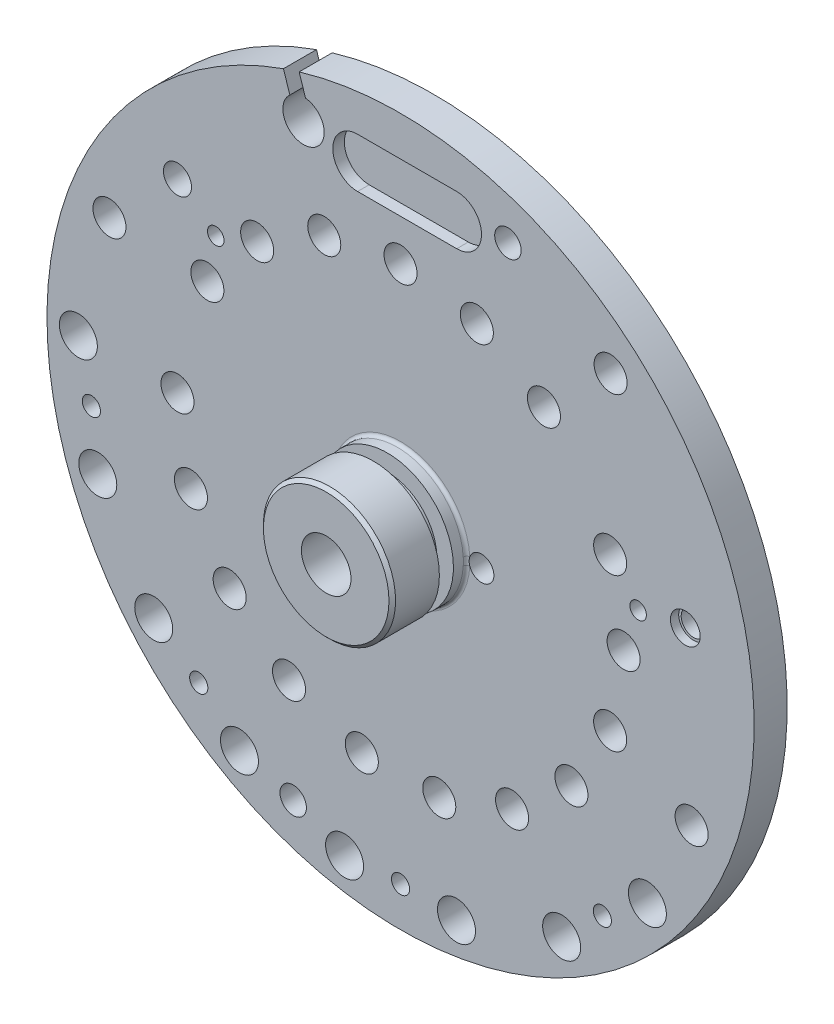
from build123d import *

# Parameters (mm, degrees)
SKETCH1_R                                            = 21.4
BOSS_EXTRUDE1_DEPTH                                  = 2
SKETCH2_R                                            = 6.5
BOSS_EXTRUDE2_DEPTH                                  = 4.7
SKETCH3_R                                            = 4
BOSS_EXTRUDE3_DEPTH                                  = 4.5
SKETCH5_R                                            = 3.25
CUT_EXTRUDE2_DEPTH                                   = 5.2
CUT_EXTRUDE1_REACH                                   = 13.2
SKETCH4_R                                            = 1.5
SKETCH6_W                                            = 0.85
SKETCH6_H                                            = 1
SKETCH7_W                                            = 0.5
SKETCH7_H                                            = 5.5
CUT_EXTRUDE3_DEPTH                                   = 22.4
CUT_EXTRUDE3_DEPTH_BACK                              = 22.4
CUT_EXTRUDE4_DEPTH                                   = 0.7
F_2_0_2_DIAMETER_HOLE6_D                             = 2
FILLET2_R                                            = 1
F_2_3_2_3_DIAMETER_HOLE1_D                           = 2.3
F_2_0_2_DIAMETER_HOLE8_D                             = 2
F_2_5_2_5_DIAMETER_HOLE1_D                           = 2.5
F_1_0_1_DIAMETER_HOLE1_D                             = 1
F_1_7_1_7_DIAMETER_HOLE2_D                           = 1.7
M1_4X0_3_TAPPED_HOLE1_D                              = 1.1
M2_TAPPED_HOLE1_D                                    = 1.6
CBORE_FOR_M1_7_HEX_SOCKET_HEAD_CAP_SCREW_D           = 1.5
CBORE_FOR_M1_7_HEX_SOCKET_HEAD_CAP_SCREW_CBORE_D     = 1.8
CBORE_FOR_M1_7_HEX_SOCKET_HEAD_CAP_SCREW_CBORE_DEPTH = 0.5
CBORE_FOR_M1_7_HEX_SOCKET_HEAD_CAP_S_2_D             = 1.5
CBORE_FOR_M1_7_HEX_SOCKET_HEAD_CAP_S_2_CBORE_D       = 1.8
CBORE_FOR_M1_7_HEX_SOCKET_HEAD_CAP_S_2_CBORE_DEPTH   = 1.2
CUT_EXTRUDE5_DEPTH                                   = 7.5
FILLET3_R                                            = 0.2
CHAMFER1_SIZE                                        = 0.2


with BuildPart() as part:
    # Sketch1 → Boss-Extrude1 (new body)
    with BuildSketch(Plane.XY):
        Circle(SKETCH1_R)
    extrude(amount=-BOSS_EXTRUDE1_DEPTH)

    # Sketch2 → Boss-Extrude2 (add)
    with BuildSketch(Plane(origin=(0, 0, -2), x_dir=(-1, 0, 0), z_dir=(0, 0, -1))):
        Circle(SKETCH2_R)
    extrude(amount=BOSS_EXTRUDE2_DEPTH)

    # Sketch3 → Boss-Extrude3 (add)
    with BuildSketch(Plane.XY):
        Circle(SKETCH3_R)
    extrude(amount=BOSS_EXTRUDE3_DEPTH)

    # Sketch5 → Cut-Extrude2 (cut)
    with BuildSketch(Plane(origin=(0, 0, -6.7), x_dir=(-1, 0, 0), z_dir=(0, 0, -1))):
        Circle(SKETCH5_R)
    extrude(amount=-CUT_EXTRUDE2_DEPTH, mode=Mode.SUBTRACT)

    # Sketch4 → Cut-Extrude1 (cut, up to next)
    with BuildSketch(Plane.XY.offset(4.5), mode=Mode.PRIVATE) as cut_extrude1_sk1:
        Circle(SKETCH4_R)
    cut_extrude1_tool1 = extrude(cut_extrude1_sk1.sketch, amount=-CUT_EXTRUDE1_REACH, mode=Mode.PRIVATE) & part.part
    add(cut_extrude1_tool1.solids().sort_by_distance((0, 0, 4.5))[0], mode=Mode.SUBTRACT)

    # Sketch6 → Cut-Revolve1 (revolve, cut)
    with BuildSketch(Plane(origin=(0, 0, 0), x_dir=(0, 0, -1), z_dir=(1, 0, 0))):
        with Locations((-1.225, 3.5)):
            Rectangle(SKETCH6_W, SKETCH6_H)
    revolve(axis=Axis((0, 0, 4.5), (0, 0, -1)), mode=Mode.SUBTRACT)

    # Sketch7 → Cut-Extrude3 (cut, two sides)
    with BuildSketch(Plane(origin=(0, 0, 0), x_dir=(0, 0, -1), z_dir=(1, 0, 0))) as cut_extrude3_sk:
        with Locations((6.45, 0)):
            Rectangle(SKETCH7_W, SKETCH7_H)
    extrude(amount=CUT_EXTRUDE3_DEPTH, mode=Mode.SUBTRACT)
    extrude(cut_extrude3_sk.sketch, amount=-CUT_EXTRUDE3_DEPTH_BACK, mode=Mode.SUBTRACT)

    # Sketch8 → Cut-Extrude4 (cut)
    with BuildSketch(Plane.XY):
        with BuildLine():
            Line((-2.6, 19), (3.4, 19))
            ThreePointArc((3.4, 19), (4.9, 17.5), (3.4, 16))
            Line((3.4, 16), (-2.6, 16))
            ThreePointArc((-2.6, 16), (-4.1, 17.5), (-2.6, 19))
        make_face()
    extrude(amount=-CUT_EXTRUDE4_DEPTH, mode=Mode.SUBTRACT)

    # Ø2.0 (2) Diameter Hole6 (through all)
    with Locations(Plane(origin=(0, 0, -2), x_dir=(1, 0, 0), z_dir=(0, 0, -1))):
        with Locations((-11.691342951, -6.75), (-8.677632731, -10.341599982), (-4.617271935, -12.685850381), (4.617271935, -12.685850381), (0, -13.5), (8.677632731, -10.341599982), (-12.685850381, 4.617271935), (-10.341599982, 8.677632731), (-6.75, 11.691342951), (2.344250399, 13.294904666), (6.75, 11.691342951), (10.341599982, 8.677632731), (12.685850381, 4.617271935), (13.5, 0), (12.685850381, -4.617271935), (-13.5, 0), (-2.344250399, 13.294904666)):
            Hole(F_2_0_2_DIAMETER_HOLE6_D / 2)

    # Fillet2
    fillet2_edges = [part.edges().sort_by_distance(p)[0] for p in [
        (6.5, 0, -2),
    ]]
    fillet(fillet2_edges, radius=FILLET2_R)

    # Ø2.3 (2.3) Diameter Hole1 (through all)
    with Locations(Plane(origin=(0, 0, -2), x_dir=(1, 0, 0), z_dir=(0, 0, -1))):
        with Locations((-19.5, 0), (-18.324006105, 6.669392795), (-14.937866641, 12.534358389), (-9.75, 16.887495374), (-3.386139465, 19.203751184), (3.386139465, 19.203751184), (9.75, 16.887495374), (14.937866641, 12.534358389)):
            Hole(F_2_3_2_3_DIAMETER_HOLE1_D / 2)

    # Ø2.0 (2) Diameter Hole8 (through all)
    with Locations(Plane(origin=(0, 0, -2), x_dir=(1, 0, 0), z_dir=(0, 0, -1))):
        with Locations((-17.616493237, -7.117525275), (12.713481521, -14.119751684), (17.616493237, 7.117525275)):
            Hole(F_2_0_2_DIAMETER_HOLE8_D / 2)

    # Ø2.5 (2.5) Diameter Hole1 (through all)
    with Locations(Plane(origin=(0, 0, -2), x_dir=(1, 0, 0), z_dir=(0, 0, -1))):
        with Locations((-5.871322893, -18.07007381)):
            Hole(F_2_5_2_5_DIAMETER_HOLE1_D / 2)

    # Ø1.0 (1) Diameter Hole1 (through all)
    with Locations(Plane(origin=(0, 0, -2), x_dir=(1, 0, 0), z_dir=(0, 0, -1))):
        with Locations((14.378193194, -2.535263394), (-11.18424887, -9.384699101)):
            Hole(F_1_0_1_DIAMETER_HOLE1_D / 2)

    # Ø1.7 (1.7) Diameter Hole2 (through all)
    with Locations(Plane(origin=(0, 0, -2), x_dir=(-1, 0, 0), z_dir=(0, 0, -1))):
        with Locations((13.5, 11.2)):
            Hole(F_1_7_1_7_DIAMETER_HOLE2_D / 2)

    # M1.4x0.3 Tapped Hole1 (through all)
    with Locations(Plane(origin=(0, 0, -2), x_dir=(1, 0, 0), z_dir=(0, 0, -1))):
        with Locations((-18.711347307, 3.299315376), (12.212964584, 14.554844419), (-12.212964584, 14.554844419), (0, 19)):
            Hole(M1_4X0_3_TAPPED_HOLE1_D / 2)

    # M2 Tapped Hole1 (through all)
    with Locations(Plane.XY):
        with Locations((6.498382723, 17.854159795), (-6.498382723, -17.854159795)):
            Hole(M2_TAPPED_HOLE1_D / 2)

    # CBORE for M1.7 Hex Socket Head Cap Screw (through all)
    with Locations(Plane.XY):
        with Locations((17.234135678, 3.038843109)):
            CounterBoreHole(CBORE_FOR_M1_7_HEX_SOCKET_HEAD_CAP_SCREW_D / 2, CBORE_FOR_M1_7_HEX_SOCKET_HEAD_CAP_SCREW_CBORE_D / 2, CBORE_FOR_M1_7_HEX_SOCKET_HEAD_CAP_SCREW_CBORE_DEPTH)

    # CBORE for M1.7 Hex Socket Head Cap S 2 (through all)
    with Locations(Plane(origin=(0, 0, -6.2), x_dir=(-1, 0, 0), z_dir=(0, 0, -1))):
        with Locations((-4.9, 0)):
            CounterBoreHole(CBORE_FOR_M1_7_HEX_SOCKET_HEAD_CAP_S_2_D / 2, CBORE_FOR_M1_7_HEX_SOCKET_HEAD_CAP_S_2_CBORE_D / 2, CBORE_FOR_M1_7_HEX_SOCKET_HEAD_CAP_S_2_CBORE_DEPTH)

    # Sketch41 → Cut-Extrude5 (cut, through all)
    with BuildSketch(Plane.XY.offset(-2)):
        with BuildLine():
            Line((-5.749818077, 19.314154426), (-6.135630169, 20.501561951))
            ThreePointArc((-6.135630169, 20.501561951), (-6.61296368, 20.352609449), (-7.086686686, 20.192544957))
            Line((-7.086686686, 20.192544957), (-6.700874593, 19.005137431))
            ThreePointArc((-6.700874593, 19.005137431), (-6.257594136, 19.258894455), (-5.749818077, 19.314154426))
        make_face()
    extrude(amount=CUT_EXTRUDE5_DEPTH, mode=Mode.SUBTRACT)

    # Fillet3
    fillet3_edges = [part.edges().sort_by_distance(p)[0] for p in [
        (-4, 0, 0),
    ]]
    fillet(fillet3_edges, radius=FILLET3_R)

    # Chamfer1
    chamfer1_edges = [part.edges().sort_by_distance(p)[0] for p in [
        (-4, 0, 4.5),
    ]]
    chamfer(chamfer1_edges, length=CHAMFER1_SIZE)


solid = part.part
